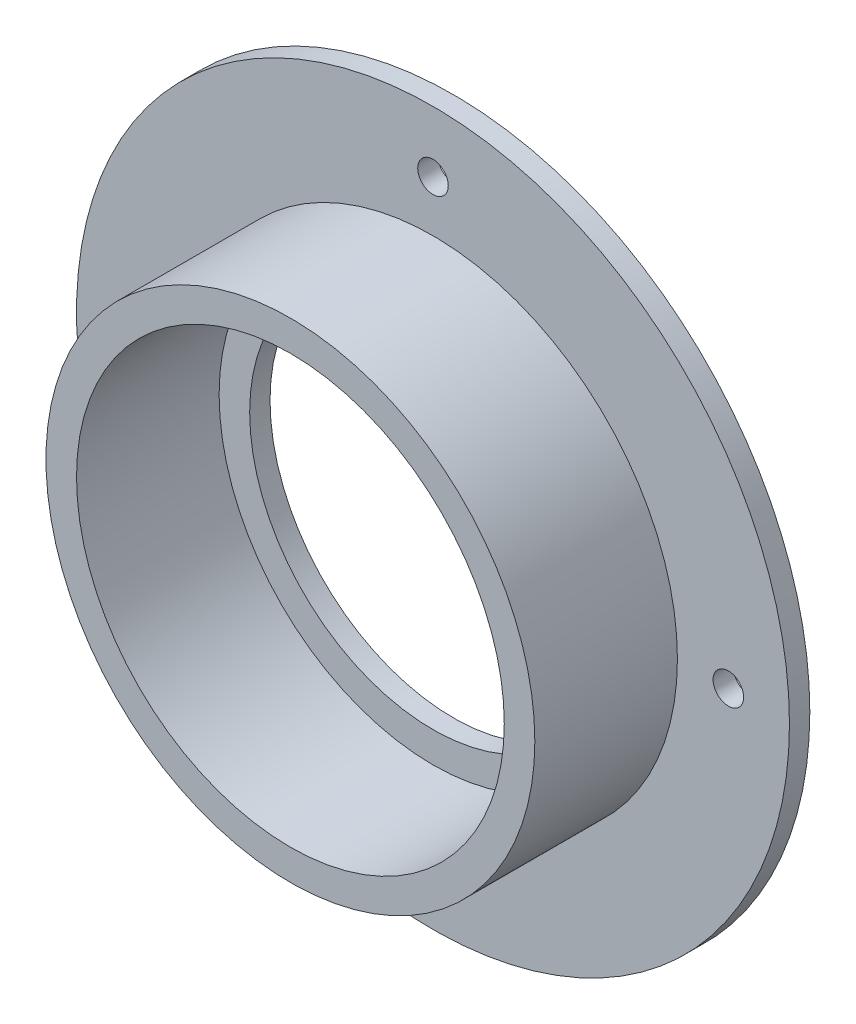
from build123d import *

# Parameters (mm, degrees)
SKETCH1_R           = 35
BOSS_EXTRUDE1_DEPTH = 2
SKETCH2_R           = 24
SKETCH2_R_2         = 21
BOSS_EXTRUDE2_DEPTH = 14
SKETCH3_R           = 21
CUT_EXTRUDE1_DEPTH  = 10
CUT_EXTRUDE2_REACH  = 18
SKETCH4_R           = 1.5
SKETCH5_R           = 21
SKETCH5_R_2         = 18
BOSS_EXTRUDE3_DEPTH = 2


with BuildPart() as part:
    # Sketch1 → Boss-Extrude1 (new body)
    with BuildSketch(Plane.XY):
        Circle(SKETCH1_R)
    extrude(amount=BOSS_EXTRUDE1_DEPTH)

    # Sketch2 → Boss-Extrude2 (add)
    with BuildSketch(Plane.XY.offset(2)):
        Circle(SKETCH2_R)
        Circle(SKETCH2_R_2, mode=Mode.SUBTRACT)
    extrude(amount=BOSS_EXTRUDE2_DEPTH)

    # Sketch3 → Cut-Extrude1 (cut)
    with BuildSketch(Plane.XY.offset(2)):
        Circle(SKETCH3_R)
    extrude(amount=-CUT_EXTRUDE1_DEPTH, mode=Mode.SUBTRACT)

    # Sketch4 → Cut-Extrude2 (cut, up to next)
    with BuildSketch(Plane(origin=(0, 0, 0), x_dir=(-1, 0, 0), z_dir=(0, 0, -1)), mode=Mode.PRIVATE) as cut_extrude2_sk1:
        with Locations((29, 0)):
            Circle(SKETCH4_R)
    cut_extrude2_tool1 = extrude(cut_extrude2_sk1.sketch, amount=-CUT_EXTRUDE2_REACH, mode=Mode.PRIVATE) & part.part
    add(cut_extrude2_tool1.solids().sort_by_distance((-29, 0, 0))[0], mode=Mode.SUBTRACT)
    # Sketch4 → Cut-Extrude2 (cut, up to next)
    with BuildSketch(Plane(origin=(0, 0, 0), x_dir=(-1, 0, 0), z_dir=(0, 0, -1)), mode=Mode.PRIVATE) as cut_extrude2_sk2:
        with Locations((0, -29)):
            Circle(SKETCH4_R)
    cut_extrude2_tool2 = extrude(cut_extrude2_sk2.sketch, amount=-CUT_EXTRUDE2_REACH, mode=Mode.PRIVATE) & part.part
    add(cut_extrude2_tool2.solids().sort_by_distance((0, -29, 0))[0], mode=Mode.SUBTRACT)
    # Sketch4 → Cut-Extrude2 (cut, up to next)
    with BuildSketch(Plane(origin=(0, 0, 0), x_dir=(-1, 0, 0), z_dir=(0, 0, -1)), mode=Mode.PRIVATE) as cut_extrude2_sk3:
        with Locations((-29, 0)):
            Circle(SKETCH4_R)
    cut_extrude2_tool3 = extrude(cut_extrude2_sk3.sketch, amount=-CUT_EXTRUDE2_REACH, mode=Mode.PRIVATE) & part.part
    add(cut_extrude2_tool3.solids().sort_by_distance((29, 0, 0))[0], mode=Mode.SUBTRACT)
    # Sketch4 → Cut-Extrude2 (cut, up to next)
    with BuildSketch(Plane(origin=(0, 0, 0), x_dir=(-1, 0, 0), z_dir=(0, 0, -1)), mode=Mode.PRIVATE) as cut_extrude2_sk4:
        with Locations((0, 29)):
            Circle(SKETCH4_R)
    cut_extrude2_tool4 = extrude(cut_extrude2_sk4.sketch, amount=-CUT_EXTRUDE2_REACH, mode=Mode.PRIVATE) & part.part
    add(cut_extrude2_tool4.solids().sort_by_distance((0, 29, 0))[0], mode=Mode.SUBTRACT)

    # Sketch5 → Boss-Extrude3 (add)
    with BuildSketch(Plane(origin=(0, 0, 0), x_dir=(-1, 0, 0), z_dir=(0, 0, -1))):
        Circle(SKETCH5_R)
        Circle(SKETCH5_R_2, mode=Mode.SUBTRACT)
    extrude(amount=-BOSS_EXTRUDE3_DEPTH)


solid = part.part
